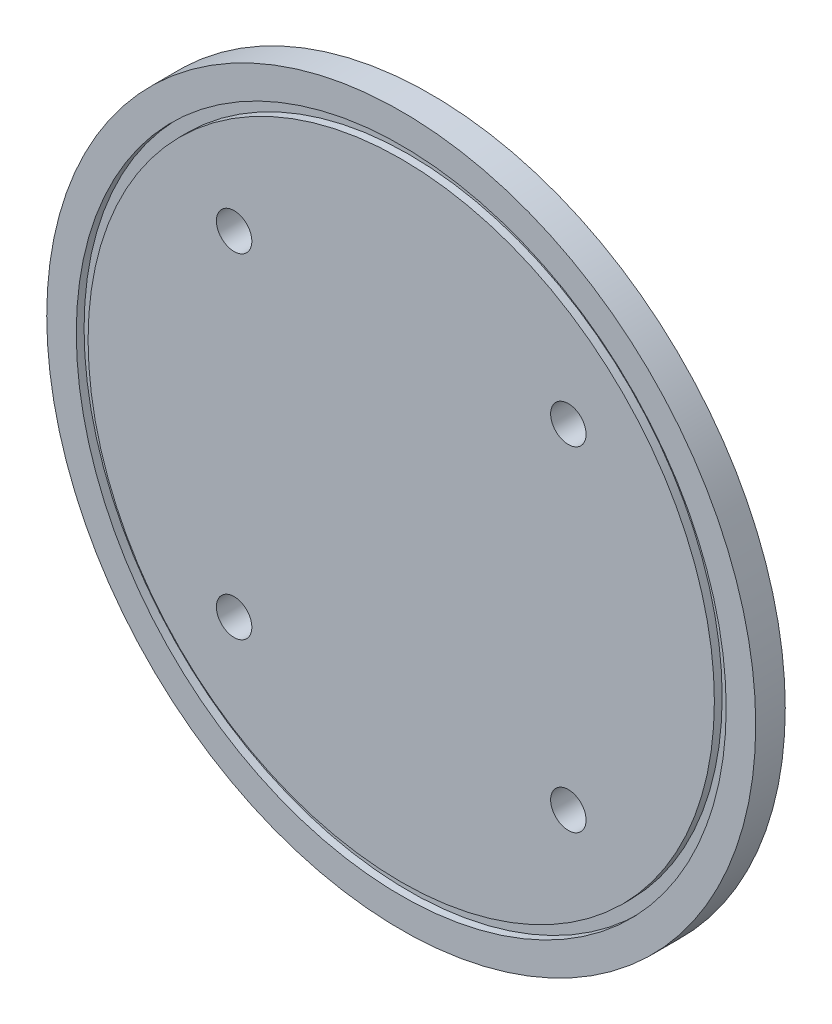
from build123d import *

# Parameters (mm, degrees)
SKETCH1_R           = 75
BOSS_EXTRUDE1_DEPTH = 5
SKETCH2_R           = 3
CUT_EXTRUDE1_DEPTH  = 5
CIRPATTERN1_COUNT   = 4
SKETCH4_R           = 55
SKETCH4_R_2         = 53
CUT_EXTRUDE3_DEPTH  = 1.3208
SKETCH5_R           = 75
SKETCH5_R_2         = 60
CUT_EXTRUDE4_DEPTH  = 5


with BuildPart() as part:
    # Sketch1 → Boss-Extrude1 (new body)
    with BuildSketch(Plane.XY):
        Circle(SKETCH1_R)
    extrude(amount=BOSS_EXTRUDE1_DEPTH)

    # Sketch2 → Cut-Extrude1 (cut)
    with BuildSketch(Plane.XY.offset(5)):
        with Locations((28.284271247, 28.284271247)):
            Circle(SKETCH2_R)
    cut_extrude1 = extrude(amount=-CUT_EXTRUDE1_DEPTH, mode=Mode.SUBTRACT)

    # CirPattern1: Cut-Extrude1 ×4 about axis
    cirpattern1_axis = Axis((0, 0, 0), (0, 0, 1))
    for i in range(1, CIRPATTERN1_COUNT):
        add(cut_extrude1.rotate(cirpattern1_axis, i * 360 / CIRPATTERN1_COUNT), mode=Mode.SUBTRACT)

    # Sketch4 → Cut-Extrude3 (cut)
    with BuildSketch(Plane.XY.offset(5)):
        Circle(SKETCH4_R)
        Circle(SKETCH4_R_2, mode=Mode.SUBTRACT)
    extrude(amount=-CUT_EXTRUDE3_DEPTH, mode=Mode.SUBTRACT)

    # Sketch5 → Cut-Extrude4 (cut)
    with BuildSketch(Plane.XY.offset(5)):
        Circle(SKETCH5_R)
        Circle(SKETCH5_R_2, mode=Mode.SUBTRACT)
    extrude(amount=-CUT_EXTRUDE4_DEPTH, mode=Mode.SUBTRACT)


solid = part.part
